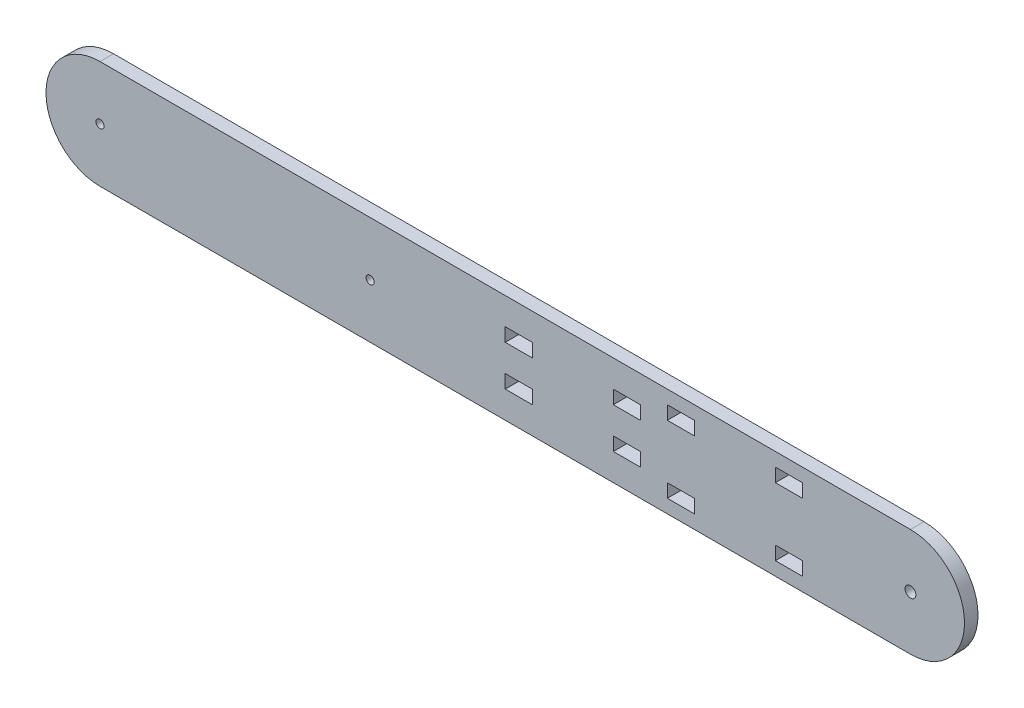
from build123d import *

# Parameters (mm, degrees)
SKETCH1_R           = 1.5
SKETCH1_R_2         = 2
SKETCH1_W           = 10
SKETCH1_H           = 5
BOSS_EXTRUDE1_DEPTH = 5


with BuildPart() as part:
    # Sketch1 → Boss-Extrude1 (new body)
    with BuildSketch(Plane.XY):
        with BuildLine():
            Line((-126.904376013, 20), (173.095623987, 20))
            ThreePointArc((173.095623987, 20), (193.095623987, 0), (173.095623987, -20))
            Line((173.095623987, -20), (-126.904376013, -20))
            ThreePointArc((-126.904376013, -20), (-146.904376013, 0), (-126.904376013, 20))
        make_face()
        with Locations((-126.904376013, 0)):
            Circle(SKETCH1_R, mode=Mode.SUBTRACT)
        with Locations((173.095623987, 0)):
            Circle(SKETCH1_R_2, mode=Mode.SUBTRACT)
        with Locations((-26.904376013, 0)):
            Circle(SKETCH1_R, mode=Mode.SUBTRACT)
        with Locations((28.095623987, 7.5)):
            Rectangle(SKETCH1_W, SKETCH1_H, mode=Mode.SUBTRACT)
        with Locations((28.095623987, -7.5)):
            Rectangle(SKETCH1_W, SKETCH1_H, mode=Mode.SUBTRACT)
        with Locations((68.095623987, 7.5)):
            Rectangle(SKETCH1_W, SKETCH1_H, mode=Mode.SUBTRACT)
        with Locations((68.095623987, -7.5)):
            Rectangle(SKETCH1_W, SKETCH1_H, mode=Mode.SUBTRACT)
        with Locations((128.095623987, -12.5)):
            Rectangle(SKETCH1_W, SKETCH1_H, mode=Mode.SUBTRACT)
        with Locations((128.095623987, 12.5)):
            Rectangle(SKETCH1_W, SKETCH1_H, mode=Mode.SUBTRACT)
        with Locations((88.095623987, -12.5)):
            Rectangle(SKETCH1_W, SKETCH1_H, mode=Mode.SUBTRACT)
        with Locations((88.095623987, 12.5)):
            Rectangle(SKETCH1_W, SKETCH1_H, mode=Mode.SUBTRACT)
    extrude(amount=BOSS_EXTRUDE1_DEPTH)


solid = part.part
